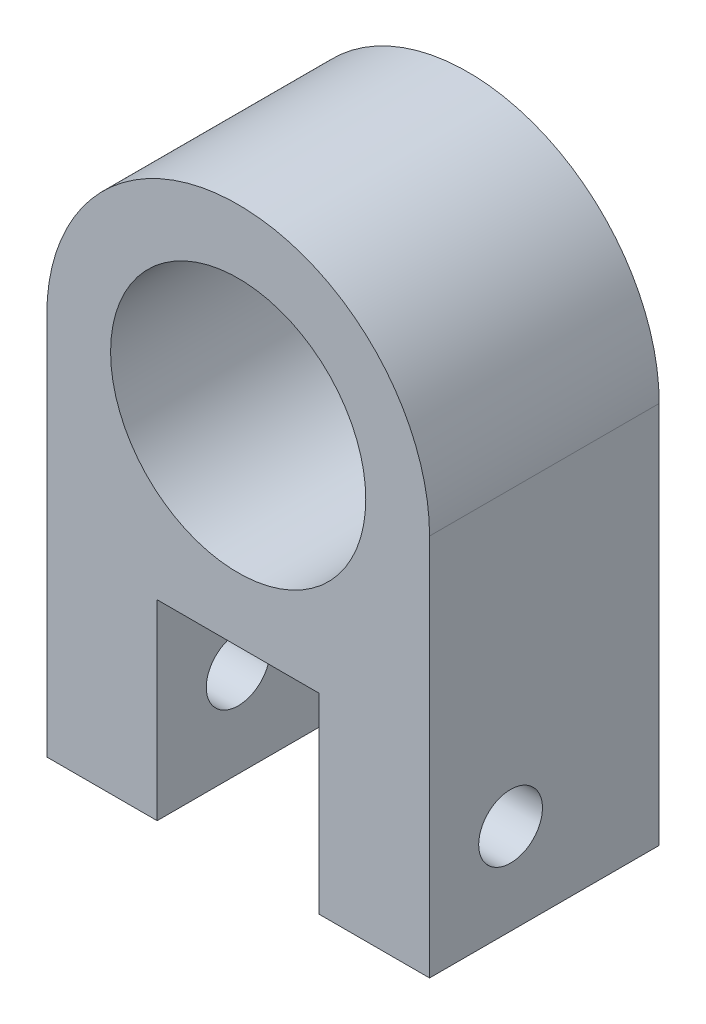
from build123d import *

# Parameters (mm, degrees)
ESQUISSE1_R             = 10
BOSS_EXTRU_1_DEPTH      = 18
ESQUISSE2_W             = 12.7
ESQUISSE2_H             = 15
ENL_V_MAT_EXTRU_1_DEPTH = 12.7
ESQUISSE3_R             = 2.5
ENL_V_MAT_EXTRU_2_DEPTH = 31


with BuildPart() as part:
    # Esquisse1 → Boss.-Extru.1 (new body)
    with BuildSketch(Plane.XY):
        with BuildLine():
            Line((0, 0), (30, 0))
            Line((30, 0), (30, 30))
            ThreePointArc((30, 30), (15, 45), (0, 30))
            Line((0, 30), (0, 0))
        make_face()
        with Locations((15, 30)):
            Circle(ESQUISSE1_R, mode=Mode.SUBTRACT)
    extrude(amount=BOSS_EXTRU_1_DEPTH)

    # Esquisse2 → Enlèv. mat.-Extru.1 (cut)
    with BuildSketch(Plane.XY.offset(18)):
        with Locations((15, 7.5)):
            Rectangle(ESQUISSE2_W, ESQUISSE2_H)
    extrude(amount=-ENL_V_MAT_EXTRU_1_DEPTH, mode=Mode.SUBTRACT)

    # Esquisse3 → Enlèv. mat.-Extru.2 (cut, through all)
    with BuildSketch(Plane.ZY):
        with Locations((11.65, 7.125)):
            Circle(ESQUISSE3_R)
    extrude(amount=-ENL_V_MAT_EXTRU_2_DEPTH, mode=Mode.SUBTRACT)


solid = part.part
